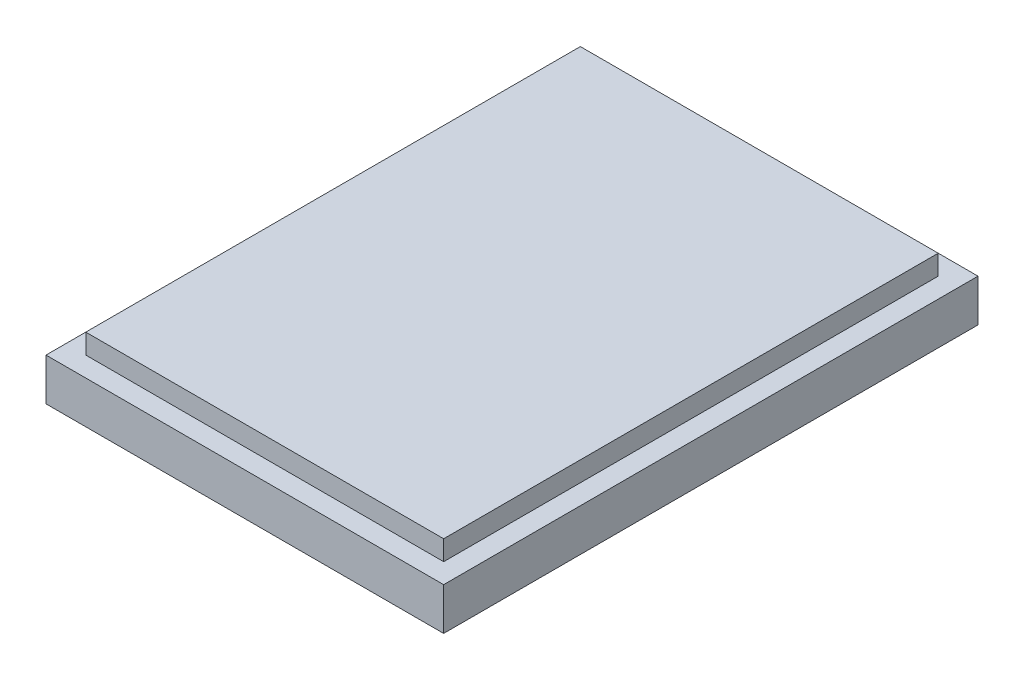
from build123d import *

# Parameters (mm, degrees)
SKETCH1_W           = 50.8
SKETCH1_H           = 68.2625
BOSS_EXTRUDE1_DEPTH = 7.9375
SKETCH2_W           = 50.8
SKETCH2_H           = 68.2625
SKETCH2_W_2         = 45.72
SKETCH2_H_2         = 63.1825
CUT_EXTRUDE1_DEPTH  = 2.54


with BuildPart() as part:
    # Sketch1 → Boss-Extrude1 (new body)
    with BuildSketch(Plane(origin=(0, 0, 0), x_dir=(1, 0, 0), z_dir=(0, 1, 0))):
        with Locations((25.4, 34.13125)):
            Rectangle(SKETCH1_W, SKETCH1_H)
    extrude(amount=BOSS_EXTRUDE1_DEPTH)

    # Sketch2 → Cut-Extrude1 (cut)
    with BuildSketch(Plane(origin=(0, 7.9375, 0), x_dir=(1, 0, 0), z_dir=(0, 1, 0))):
        with Locations((25.4, 34.13125)):
            Rectangle(SKETCH2_W, SKETCH2_H)
        with Locations((25.4, 34.13125)):
            Rectangle(SKETCH2_W_2, SKETCH2_H_2, mode=Mode.SUBTRACT)
    extrude(amount=-CUT_EXTRUDE1_DEPTH, mode=Mode.SUBTRACT)


solid = part.part
